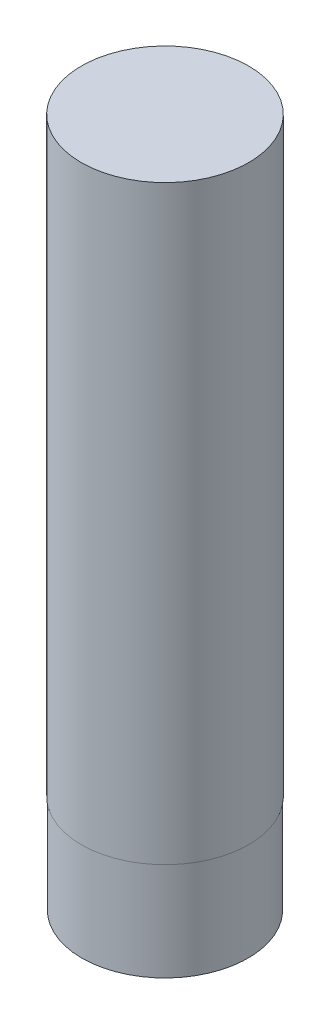
from build123d import *

# Parameters (mm, degrees)
SKETCH1_R           = 8.5
BOSS_EXTRUDE1_DEPTH = 60
SKETCH2_R           = 8.45
BOSS_EXTRUDE2_DEPTH = 10


with BuildPart() as part:
    # Sketch1 → Boss-Extrude1 (new body)
    with BuildSketch(Plane(origin=(0, 0, 0), x_dir=(1, 0, 0), z_dir=(0, 1, 0))):
        Circle(SKETCH1_R)
    extrude(amount=BOSS_EXTRUDE1_DEPTH)

    # Sketch2 → Boss-Extrude2 (add)
    with BuildSketch(Plane.XZ):
        Circle(SKETCH2_R)
    extrude(amount=BOSS_EXTRUDE2_DEPTH)


solid = part.part
